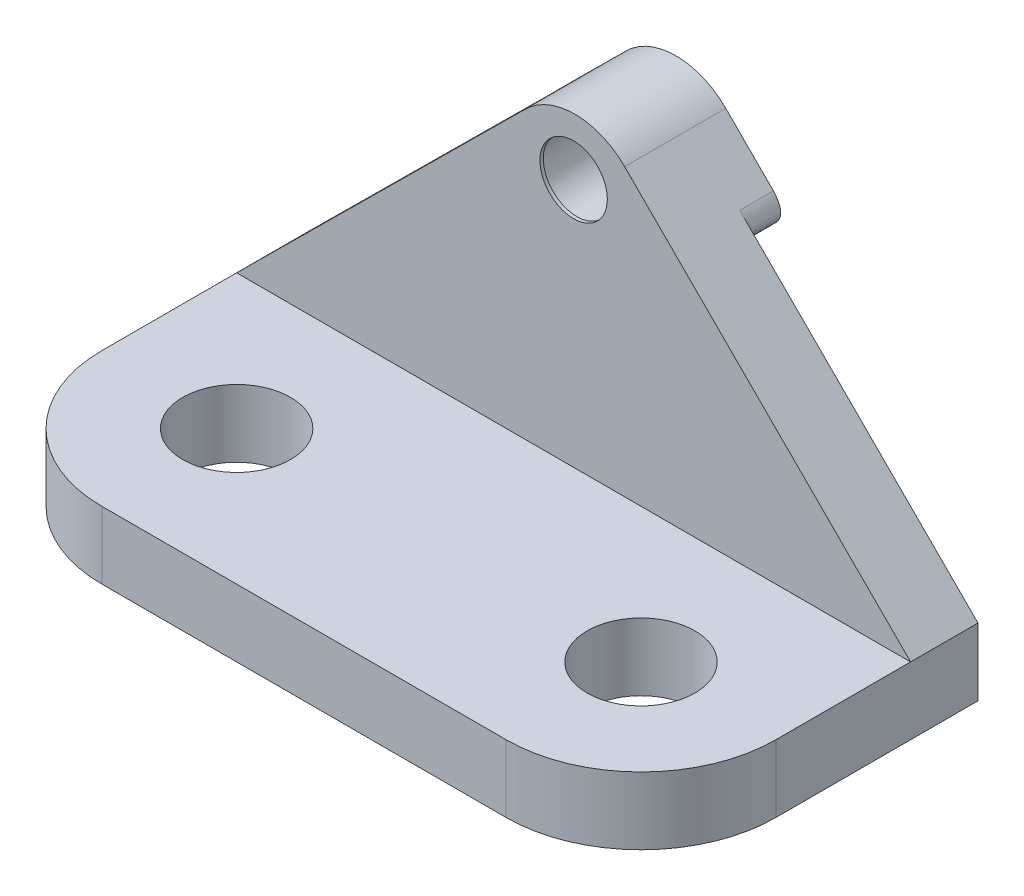
from build123d import *

# Parameters (mm, degrees)
SKETCH1_W           = 50
SKETCH1_H           = 25
SKETCH1_R           = 4
BOSS_EXTRUDE1_DEPTH = 5
FILLET1_R           = 10
BOSS_EXTRUDE3_DEPTH = 5
BOSS_EXTRUDE4_DEPTH = 2.5
SKETCH10_R          = 2.5
CUT_EXTRUDE1_DEPTH  = 47.377762273
SKETCH11_R          = 2.75
CUT_EXTRUDE3_DEPTH  = 7.25


with BuildPart() as part:
    # Sketch1 → Boss-Extrude1 (new body)
    with BuildSketch(Plane(origin=(0, 0, 0), x_dir=(1, 0, 0), z_dir=(0, 1, 0))):
        Rectangle(SKETCH1_W, SKETCH1_H)
        with Locations(Location((-15, -2.5, 0), (0, 0, 270))):
            Circle(SKETCH1_R, mode=Mode.SUBTRACT)
        with Locations(Location((15, -2.5, 0), (0, 0, 270))):
            Circle(SKETCH1_R, mode=Mode.SUBTRACT)
    extrude(amount=BOSS_EXTRUDE1_DEPTH)

    # Fillet1
    fillet1_edges = [part.edges().sort_by_distance(p)[0] for p in [
        (25, 2.5, 12.5),
        (-25, 2.5, 12.5),
    ]]
    fillet(fillet1_edges, radius=FILLET1_R)

    # Sketch8 → Boss-Extrude3 (add)
    with BuildSketch(Plane(origin=(0, 0, -12.5), x_dir=(-1, 0, 0), z_dir=(0, 0, -1))):
        with BuildLine():
            Line((-25, 5), (-3.786796564, 26.213203436))
            ThreePointArc((-3.786796564, 26.213203436), (-0.027585498, 27.742077627), (3.691067032, 26.117039939))
            Line((3.691067032, 26.117039939), (25, 5))
            Line((25, 5), (25, 0))
            Line((25, 0), (-25, 0))
            Line((-25, 0), (-25, 5))
        make_face()
    extrude(amount=-BOSS_EXTRUDE3_DEPTH)

    # Sketch9 → Boss-Extrude4 (add)
    with BuildSketch(Plane(origin=(0, 0, -12.5), x_dir=(-1, 0, 0), z_dir=(0, 0, -1))):
        with BuildLine():
            Line((-3.786796564, 26.213203436), (-7.32233047, 22.67766953))
            add(Edge.make_bspline(
                [(-7.32233047, 22.67766953), (-8.178452668, 21.703073606), (-8.02278568, 20.898176811), (-6.855329509, 20.262979147)],
                knots=[0, 0, 0, 0, 1, 1, 1, 1], degree=3))
            ThreePointArc((-6.855329509, 20.262979147), (0.019478922, 18.507671395), (6.900130368, 20.239933483))
            add(Edge.make_bspline(
                [(7.24255586, 22.597533282), (8.702325763, 21.238811855), (6.900130368, 20.239933483)],
                knots=[0, 0, 0, 1, 1, 1], degree=2))
            Line((7.24255586, 22.597533282), (3.691067032, 26.117039939))
            ThreePointArc((3.691067032, 26.117039939), (-0.027585498, 27.742077627), (-3.786796564, 26.213203436))
        make_face()
    extrude(amount=BOSS_EXTRUDE4_DEPTH)

    # Sketch10 → Cut-Extrude1 (cut, through all)
    with BuildSketch(Plane(origin=(0, 0, -15), x_dir=(-1, 0, 0), z_dir=(0, 0, -1))):
        with Locations((0, 23.478841553)):
            Circle(SKETCH10_R)
    extrude(amount=-CUT_EXTRUDE1_DEPTH, mode=Mode.SUBTRACT)

    # Sketch11 → Cut-Extrude3 (cut)
    with BuildSketch(Plane(origin=(0, 0, -15), x_dir=(-1, 0, 0), z_dir=(0, 0, -1))):
        with Locations((0, 23.478841553)):
            Circle(SKETCH11_R)
    extrude(amount=-CUT_EXTRUDE3_DEPTH, mode=Mode.SUBTRACT)


solid = part.part
